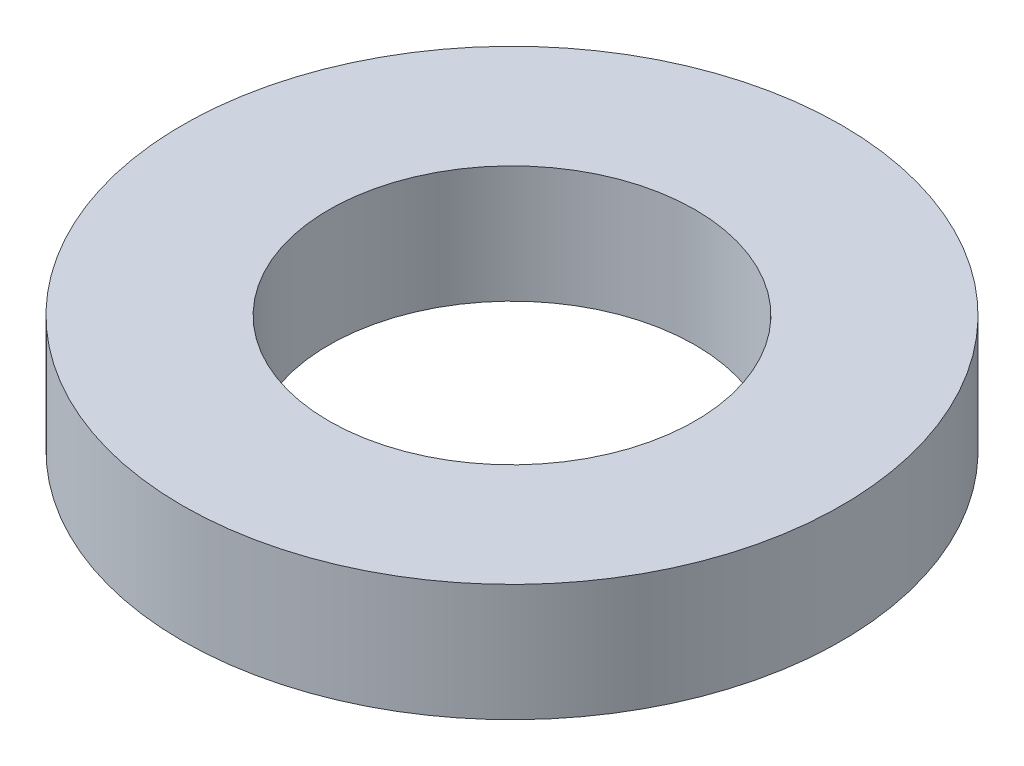
from build123d import *

# Parameters (mm, degrees)
SKETCH_1_R      = 22.5
SKETCH_1_R_2    = 12.5
EXTRUDE_1_DEPTH = 4


with BuildPart() as part:
    # 草图1 → 凸台-拉伸1 (new body, symmetric)
    with BuildSketch(Plane(origin=(0, 0, 0), x_dir=(1, 0, 0), z_dir=(0, 1, 0))):
        Circle(SKETCH_1_R)
        Circle(SKETCH_1_R_2, mode=Mode.SUBTRACT)
    extrude(amount=EXTRUDE_1_DEPTH, both=True)


solid = part.part
